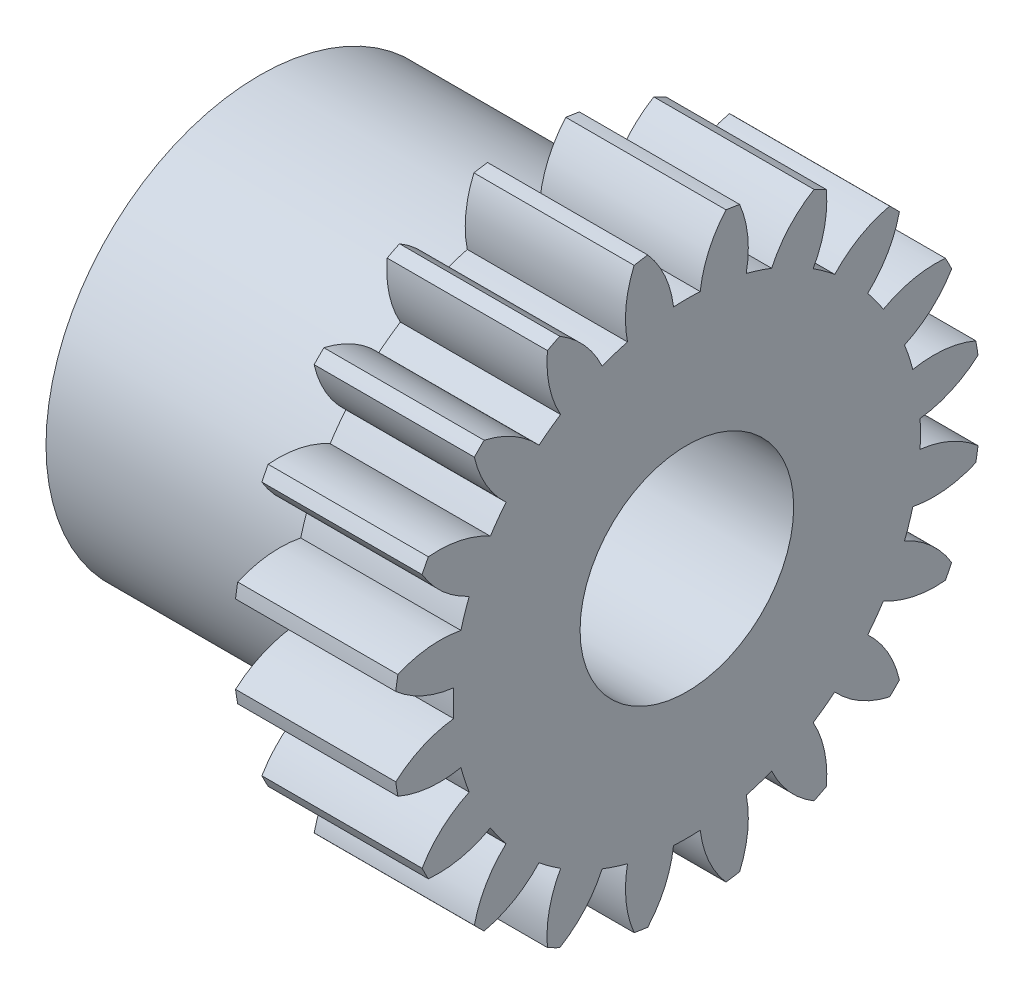
from build123d import *

# Parameters (mm, degrees)
BASPROSKE_W      = 3
BASPROSKE_H      = 5.5
TOOTHCUT_DEPTH   = 9.336666
TEETHCUTS_COUNT  = 20
TEETHCUTS_ANGLE  = 342
HUBNEAONESKE_R   = 4
HUBNEARONE_DEPTH = 5.0000508
BORSKE_R         = 2
BORE_DEPTH       = 8.0000508


with BuildPart() as part:
    # BasProSke → Base-Revolve (revolve)
    with BuildSketch(Plane(origin=(0, 0, 0), x_dir=(1, 0, 0), z_dir=(0, 1, 0)), mode=Mode.PRIVATE) as base_revolve_sk:
        with Locations((1.5, 2.75)):
            Rectangle(BASPROSKE_W, BASPROSKE_H)
    revolve(base_revolve_sk.sketch.rotate(Axis((-10, 0, 0), (1, 0, 0)), 180), axis=Axis((-10, 0, 0), (1, 0, 0)))

    # TooCutSke → ToothCut (cut, through all)
    with BuildSketch(Plane(origin=(0, 0, 0), x_dir=(0, 0, -1), z_dir=(1, 0, 0))):
        with BuildLine():
            ThreePointArc((0.249903181, 4.366855207), (0, 4.374), (-0.249903181, 4.366855207))
            ThreePointArc((-0.249903181, 4.366855207), (-0.415207844, 4.95951031), (-0.752843848, 5.473871692))
            ThreePointArc((-0.752843848, 5.473871692), (0, 5.5254), (0.752843848, 5.473871692))
            ThreePointArc((0.752843848, 5.473871692), (0.415207844, 4.95951031), (0.249903181, 4.366855207))
        make_face()
    toothcut = extrude(amount=TOOTHCUT_DEPTH, mode=Mode.SUBTRACT)

    # TeethCuts: ToothCut ×20 about axis
    teethcuts_axis = Axis((-10, 0, 0), (1, 0, 0))
    for i in range(1, TEETHCUTS_COUNT):
        add(toothcut.rotate(teethcuts_axis, i * TEETHCUTS_ANGLE / (TEETHCUTS_COUNT - 1)), mode=Mode.SUBTRACT)

    # HubNeaOneSke → HubNearOne (add)
    with BuildSketch(Plane.ZY):
        with Locations(Location((0, 0, 0), (0, 0, 180))):
            Circle(HUBNEAONESKE_R)
    extrude(amount=HUBNEARONE_DEPTH)

    # BorSke → Bore (cut, symmetric)
    with BuildSketch(Plane(origin=(0, 0, 0), x_dir=(0, 0, -1), z_dir=(1, 0, 0))):
        with Locations(Location((0, 0, 0), (0, 0, 180))):
            Circle(BORSKE_R)
    extrude(amount=BORE_DEPTH, both=True, mode=Mode.SUBTRACT)


solid = part.part
